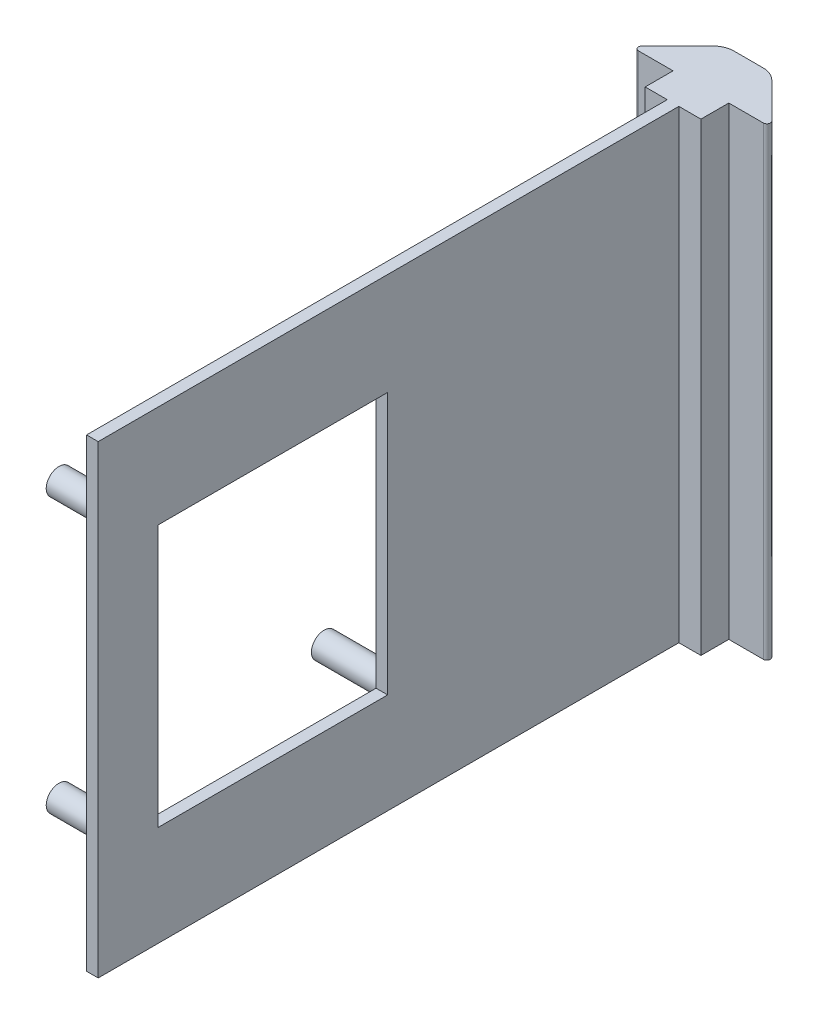
from build123d import *

# Parameters (mm, degrees)
BOSS_EXTRUDE1_DEPTH = 50.8
SKETCH2_R           = 1.397
BOSS_EXTRUDE3_DEPTH = 7.62
SKETCH4_W           = 25.11
SKETCH4_H           = 28.65
CUT_EXTRUDE2_DEPTH  = 8.846923164


with BuildPart() as part:
    # Sketch1 → Boss-Extrude1 (new body)
    with BuildSketch(Plane(origin=(0, 273.183078415, 0), x_dir=(1, 0, 0), z_dir=(0, 1, 0))):
        with BuildLine():
            Line((-29.667642961, -22.342314993), (-29.667642961, -22.596314993))
            Line((-29.667642961, -22.596314993), (-27.254642961, -22.596314993))
            Line((-27.254642961, -22.596314993), (-27.254642961, -86.096314993))
            Line((-27.254642961, -86.096314993), (-25.984642961, -86.096314993))
            Line((-25.984642961, -86.096314993), (-25.984642961, -22.596314993))
            Line((-25.984642961, -22.596314993), (-23.571642961, -22.596314993))
            Line((-23.571642961, -22.596314993), (-23.571642961, -22.342314993))
            Line((-23.571642961, -22.342314993), (-23.571642961, -19.548314993))
            Line((-23.571642961, -19.548314993), (-19.788719797, -19.548314993))
            ThreePointArc((-19.788719797, -19.548314993), (-19.436721695, -19.313117381), (-19.519312114, -18.897907309))
            Line((-19.519312114, -18.897907309), (-23.406350532, -15.010868891))
            ThreePointArc((-23.406350532, -15.010868891), (-24.147982307, -14.515326382), (-25.022796633, -14.341314993))
            Line((-25.022796633, -14.341314993), (-28.216489288, -14.341314993))
            ThreePointArc((-28.216489288, -14.341314993), (-29.091303615, -14.515326382), (-29.83293539, -15.010868891))
            Line((-29.83293539, -15.010868891), (-33.719973808, -18.897907309))
            ThreePointArc((-33.719973808, -18.897907309), (-33.802564226, -19.313117381), (-33.450566125, -19.548314993))
            Line((-33.450566125, -19.548314993), (-29.667642961, -19.548314993))
            Line((-29.667642961, -19.548314993), (-29.667642961, -22.342314993))
        make_face()
    extrude(amount=-BOSS_EXTRUDE1_DEPTH)

    # Sketch2 → Boss-Extrude3 (add)
    with BuildSketch(Plane.ZY.offset(27.254642961)):
        with Locations((52.494743656, 232.690269259)):
            Circle(SKETCH2_R)
        with Locations((52.494743656, 262.690269259)):
            Circle(SKETCH2_R)
        with Locations((81.494743656, 262.690269259)):
            Circle(SKETCH2_R)
        with Locations((81.494743656, 232.690269259)):
            Circle(SKETCH2_R)
    extrude(amount=BOSS_EXTRUDE3_DEPTH)

    # Sketch4 → Cut-Extrude2 (cut, through all)
    with BuildSketch(Plane.ZY.offset(27.254642961)):
        with Locations((66.994743656, 247.690269259)):
            Rectangle(SKETCH4_W, SKETCH4_H)
    extrude(amount=-CUT_EXTRUDE2_DEPTH, mode=Mode.SUBTRACT)


solid = part.part
